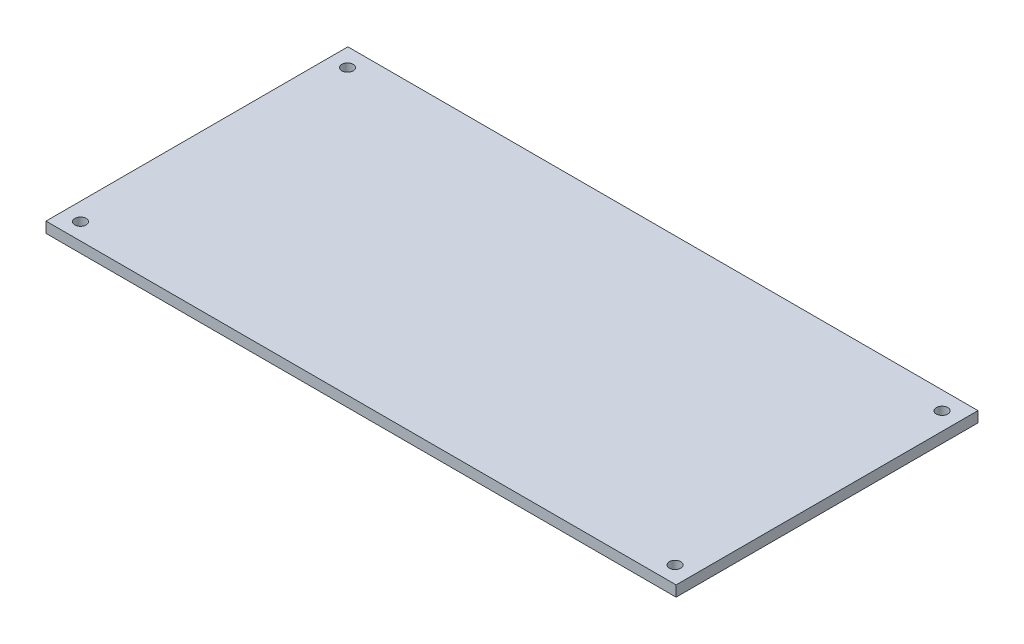
from build123d import *

# Parameters (mm, degrees)
SKETCH1_W           = 177
SKETCH1_H           = 84.8
BOSS_EXTRUDE1_DEPTH = 3
SKETCH2_R           = 1.6
CUT_EXTRUDE1_DEPTH  = 4


with BuildPart() as part:
    # Sketch1 → Boss-Extrude1 (new body)
    with BuildSketch(Plane(origin=(0, 0, 0), x_dir=(1, 0, 0), z_dir=(0, 1, 0))):
        Rectangle(SKETCH1_W, SKETCH1_H)
    extrude(amount=BOSS_EXTRUDE1_DEPTH)

    # Sketch2 → Cut-Extrude1 (cut, through all)
    with BuildSketch(Plane(origin=(0, 3, 0), x_dir=(1, 0, 0), z_dir=(0, 1, 0))):
        with Locations((83.5, -37.7)):
            Circle(SKETCH2_R)
        with Locations((83.5, 37.3)):
            Circle(SKETCH2_R)
        with Locations((-83.5, 37.3)):
            Circle(SKETCH2_R)
        with Locations((-83.5, -37.7)):
            Circle(SKETCH2_R)
    extrude(amount=-CUT_EXTRUDE1_DEPTH, mode=Mode.SUBTRACT)


solid = part.part
